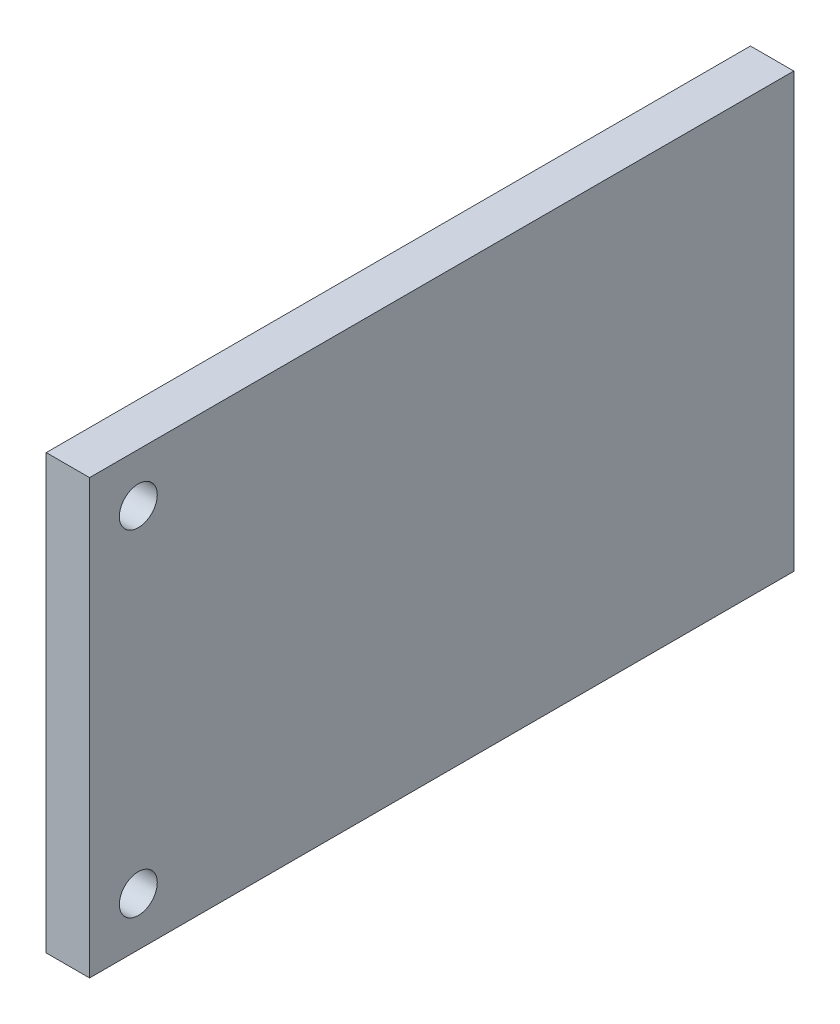
from build123d import *

# Parameters (mm, degrees)
SKETCH1_W                   = 80
SKETCH1_H                   = 130
SKETCH1_R                   = 3.5
BOSS_EXTRUDE1_DEPTH         = 8
DODANIE_WYCI_GNI_CIE1_DEPTH = 6
SZKIC2_W                    = 2
SZKIC2_H                    = 6
WYTNIJ_WYCI_GNI_CIE1_DEPTH  = 40


with BuildPart() as part:
    # Sketch1 → Boss-Extrude1 (new body)
    with BuildSketch(Plane(origin=(0, 0, 0), x_dir=(0, -1, 0), z_dir=(-1, 0, 0))):
        with Locations((-35, 60)):
            Rectangle(SKETCH1_W, SKETCH1_H)
        with Locations((-66, 116)):
            Circle(SKETCH1_R, mode=Mode.SUBTRACT)
        with Locations((-4, 116)):
            Circle(SKETCH1_R, mode=Mode.SUBTRACT)
    extrude(amount=-BOSS_EXTRUDE1_DEPTH)

    # Szkic1 → Dodanie-wyciągnięcie1 (add)
    with BuildSketch(Plane.ZY):
        Polygon((-3.873206623, 3.873206623), (3.197861189, -3.197861189), (6.733395095, 0.337672717), (-0.337672717, 7.408740528), align=None)
        Polygon((20.875530719, 28.621943964), (27.946598531, 21.550876152), (31.482132437, 25.086410058), (24.411064625, 32.15747787), align=None)
    extrude(amount=DODANIE_WYCI_GNI_CIE1_DEPTH)

    # Szkic2 → Wytnij-wyciągnięcie1 (cut)
    with BuildSketch(Plane(origin=(0, 0, 0), x_dir=(1, 0, 0), z_dir=(0, -0.707106781, -0.707106781))):
        with Locations((-3, -0.477541336)):
            Rectangle(SZKIC2_W, SZKIC2_H)
    extrude(amount=-WYTNIJ_WYCI_GNI_CIE1_DEPTH, mode=Mode.SUBTRACT)


solid = part.part
